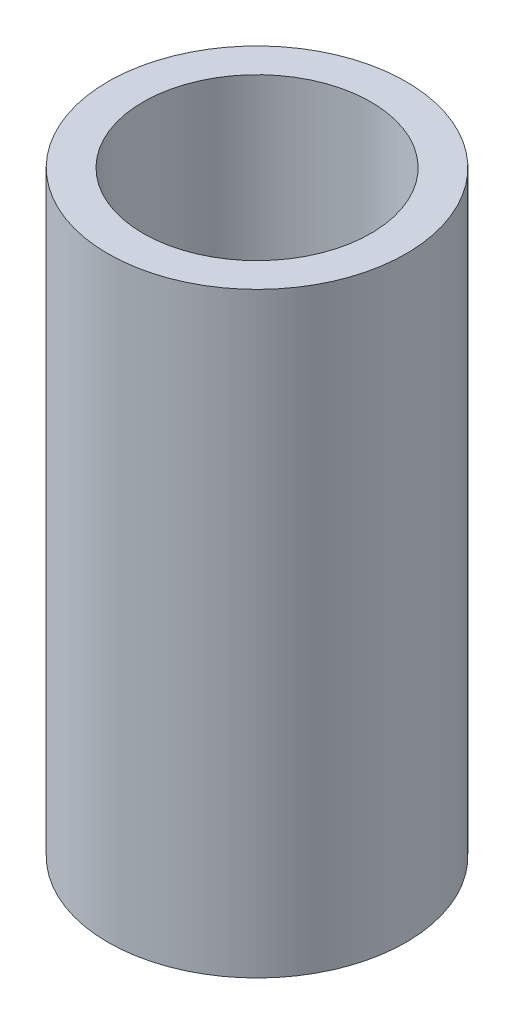
from build123d import *

# Parameters (mm, degrees)
SKETCH1_R      = 57.15
SKETCH1_R_2    = 43.6626
EXTRUDE1_DEPTH = 114.3


with BuildPart() as part:
    # Sketch1 → Extrude1 (new body, symmetric)
    with BuildSketch(Plane(origin=(0, 0, 0), x_dir=(1, 0, 0), z_dir=(0, 1, 0))):
        Circle(SKETCH1_R)
        Circle(SKETCH1_R_2, mode=Mode.SUBTRACT)
    extrude(amount=EXTRUDE1_DEPTH, both=True)


solid = part.part
